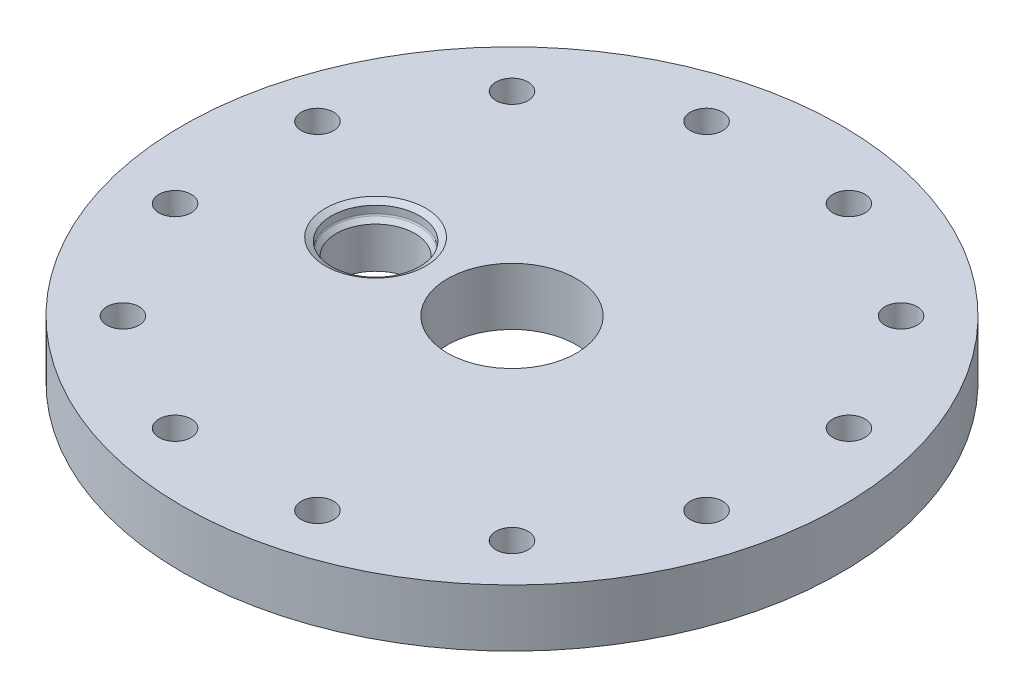
from build123d import *

# Parameters (mm, degrees)
TOP_PLATE_DIAMETER_R           = 73.025
TOP_PLATE_EXTRUDE_DEPTH        = 12.7
FUEL_PORT_CLEARANCE_DIAMETER_R = 14.2875
FUEL_PORT_CLEARANCE_HOLE_DEPTH = 105.050907012
ASSEMBLY_BOLT_REACH            = 106.051
ASSEMBLY_BOLT_DIAMETER_R       = 3.571875
CIRPATTERN1_COUNT              = 12
LOX_PORT_REACH                 = 106.051
SKETCH7_R                      = 8.7122


with BuildPart() as part:
    # Top Plate Diameter → Top Plate Extrude (new body)
    with BuildSketch(Plane(origin=(0, 0, 0), x_dir=(1, 0, 0), z_dir=(0, 1, 0))):
        Circle(TOP_PLATE_DIAMETER_R)
    extrude(amount=TOP_PLATE_EXTRUDE_DEPTH)

    # Fuel Port Clearance Diameter → Fuel Port Clearance Hole (cut, through all)
    with BuildSketch(Plane(origin=(0, 12.7, 0), x_dir=(1, 0, 0), z_dir=(0, 1, 0))):
        Circle(FUEL_PORT_CLEARANCE_DIAMETER_R)
    extrude(amount=-FUEL_PORT_CLEARANCE_HOLE_DEPTH, mode=Mode.SUBTRACT)

    # Assembly Bolt Diameter → Assembly Bolt (cut, up to next)
    with BuildSketch(Plane(origin=(0, 12.7, 0), x_dir=(1, 0, 0), z_dir=(0, 1, 0)), mode=Mode.PRIVATE) as assembly_bolt_sk1:
        with Locations((-58.882838371, 15.777608989)):
            Circle(ASSEMBLY_BOLT_DIAMETER_R)
    assembly_bolt_tool1 = extrude(assembly_bolt_sk1.sketch, amount=-ASSEMBLY_BOLT_REACH, mode=Mode.PRIVATE) & part.part
    assembly_bolt = assembly_bolt_tool1.solids().sort_by_distance((-58.882838, 12.7, -15.777609))[0]
    add(assembly_bolt, mode=Mode.SUBTRACT)

    # CirPattern1: Assembly Bolt ×12 about axis
    cirpattern1_axis = Axis((0, 12.7, 0), (0, -1, 0))
    for i in range(1, CIRPATTERN1_COUNT):
        add(assembly_bolt.rotate(cirpattern1_axis, i * 360 / CIRPATTERN1_COUNT), mode=Mode.SUBTRACT)

    # Sketch7 → LOX Port (cut, up to next)
    with BuildSketch(Plane(origin=(0, 12.7, 0), x_dir=(1, 0, 0), z_dir=(0, 1, 0)), mode=Mode.PRIVATE) as lox_port_sk1:
        with Locations((-30.226, 0)):
            Circle(SKETCH7_R)
    lox_port_tool1 = extrude(lox_port_sk1.sketch, amount=-LOX_PORT_REACH, mode=Mode.PRIVATE) & part.part
    add(lox_port_tool1.solids().sort_by_distance((-30.226, 12.7, 0))[0], mode=Mode.SUBTRACT)

    # Sketch9 → Cut-Revolve1 (revolve, cut)
    with BuildSketch(Plane.XY):
        with BuildLine():
            Line((-41.3385, 12.7), (-39.9923, 11.922771068))
            Line((-39.9923, 11.922771068), (-39.9923, 10.3124))
            ThreePointArc((-39.9923, 10.3124), (-39.953630803, 10.117996816), (-39.843510245, 9.953189755))
            Line((-39.843510245, 9.953189755), (-38.9382, 9.04787951))
            Line((-38.9382, 9.04787951), (-38.9382, 12.7))
            Line((-38.9382, 12.7), (-41.3385, 12.7))
        make_face()
    revolve(axis=Axis((-30.226, -7.468881995, 0), (0, 1, 0)), mode=Mode.SUBTRACT)


solid = part.part
